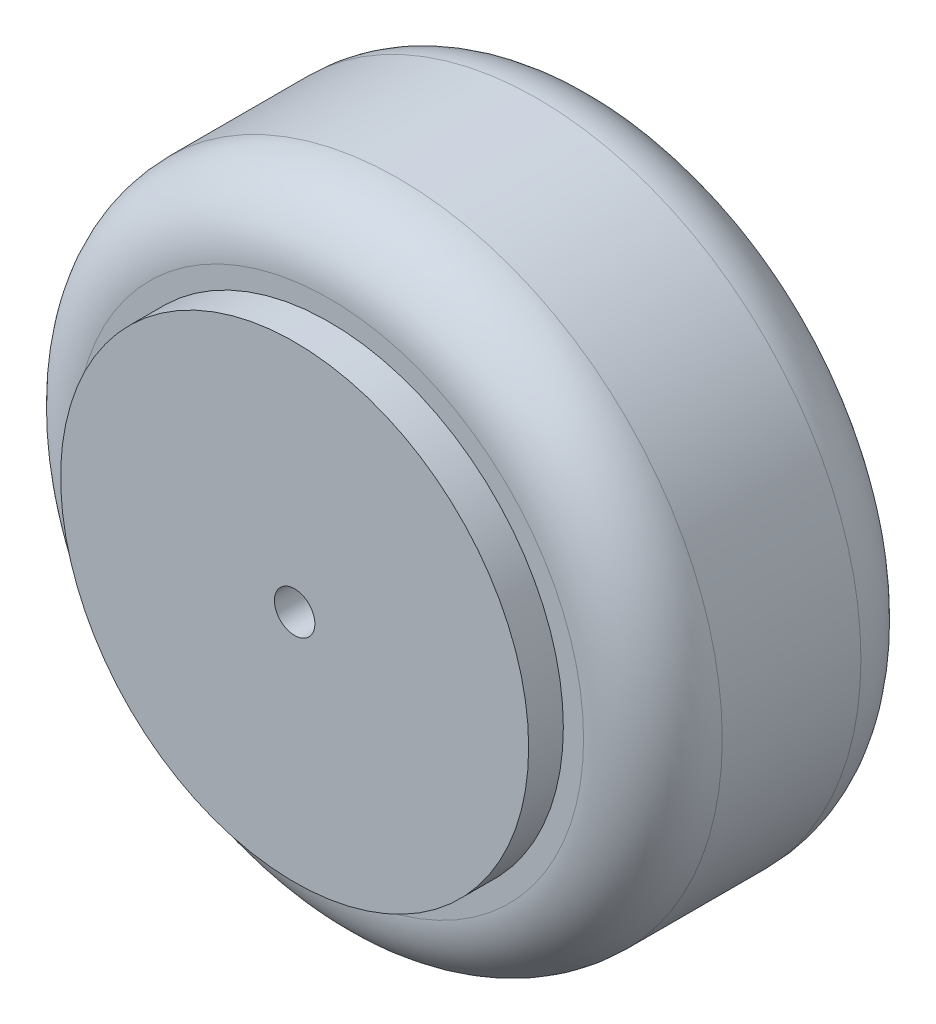
from build123d import *

# Parameters (mm, degrees)
SKETCH1_R               = 40.5
BOSS_EXTRUDE1_DEPTH     = 6
SKETCH2_W               = 40
SKETCH2_H               = 48
FILLET1_R               = 12
SKETCH4_R               = 16
BOSS_EXTRUDE2_DEPTH     = 34
SKETCH5_R               = 3.5
CUT_EXTRUDE1_DEPTH      = 15.0000001
CUT_EXTRUDE1_DEPTH_BACK = 41


with BuildPart() as part:
    # Sketch1 → Boss-Extrude1 (new body)
    with BuildSketch(Plane.XY):
        Circle(SKETCH1_R)
    extrude(amount=BOSS_EXTRUDE1_DEPTH)

    # Sweep1: sweep along a path in Sketch3
    with BuildLine(Plane.XY.offset(-24)) as sweep1_path:
        CenterArc((0, 0), 70, 0, 360)
    # Sketch2 → Sweep1 (sweep)
    with BuildSketch(Plane(origin=(0, 0, 0), x_dir=(1, 0, 0), z_dir=(0, 1, 0))):
        with Locations((36, 24)):
            Rectangle(SKETCH2_W, SKETCH2_H)
    sweep(path=sweep1_path.line)

    # Fillet1
    fillet1_edges = [part.edges().sort_by_distance(p)[0] for p in [
        (-16, 0, -48),
        (-56, 0, -48),
        (-56, 0, 0),
    ]]
    fillet(fillet1_edges, radius=FILLET1_R)

    # Sketch4 → Boss-Extrude2 (add)
    with BuildSketch(Plane(origin=(0, 0, 0), x_dir=(-1, 0, 0), z_dir=(0, 0, -1))):
        Circle(SKETCH4_R)
    extrude(amount=BOSS_EXTRUDE2_DEPTH)

    # Sketch5 → Cut-Extrude1 (cut, two sides)
    with BuildSketch(Plane(origin=(0, 0, -34), x_dir=(-1, 0, 0), z_dir=(0, 0, -1))) as cut_extrude1_sk:
        Circle(SKETCH5_R)
    extrude(amount=CUT_EXTRUDE1_DEPTH, mode=Mode.SUBTRACT)
    extrude(cut_extrude1_sk.sketch, amount=-CUT_EXTRUDE1_DEPTH_BACK, mode=Mode.SUBTRACT)


solid = part.part
